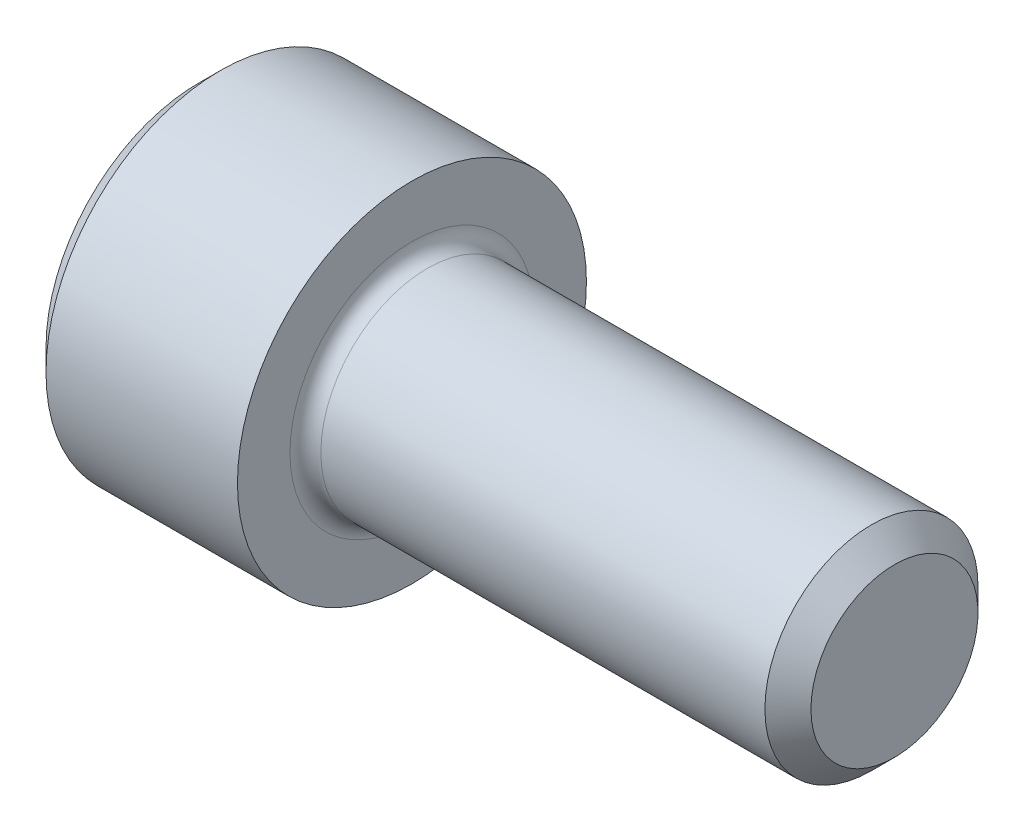
from build123d import *

# Parameters (mm, degrees)
FILLET1_R   = 0.254
HEX_2_DEPTH = 1.6256


with BuildPart() as part:
    # BodySke → Base-Revolve (revolve)
    with BuildSketch(Plane.XY):
        Polygon((0, 0), (0, 2.5146), (0.3556, 2.8702), (3.5052, 2.8702), (3.5052, 1.7526), (11.06424, 1.7526), (11.4427, 1.37414), (11.4427, 0), align=None)
    revolve(axis=Axis((-31.75, 0, 0), (1, 0, 0)))

    # Fillet1
    fillet1_edges = [part.edges().sort_by_distance(p)[0] for p in [
        (3.5052, -1.7526, 0),
    ]]
    fillet(fillet1_edges, radius=FILLET1_R)

    # Sketch2 → Hex-PreBroach (revolve, cut)
    with BuildSketch(Plane.XY):
        Polygon((0, 1.3843), (1.6256, 1.3843), (2.424825978, 0), (0, 0), align=None)
    revolve(axis=Axis((0, 0, 0), (1, 0, 0)), mode=Mode.SUBTRACT)

    # Sketch3 → Hex 2 (cut)
    with BuildSketch(Plane(origin=(0, 0, 0), x_dir=(0, 0.5, 0.866025404), z_dir=(-1, 0, 0))):
        Polygon((0.799225978, 1.3843), (-0.799225978, 1.3843), (-1.598451955, 0), (-0.799225978, -1.3843), (0.799225978, -1.3843), (1.598451955, 0), align=None)
    extrude(amount=-HEX_2_DEPTH, mode=Mode.SUBTRACT)


solid = part.part
